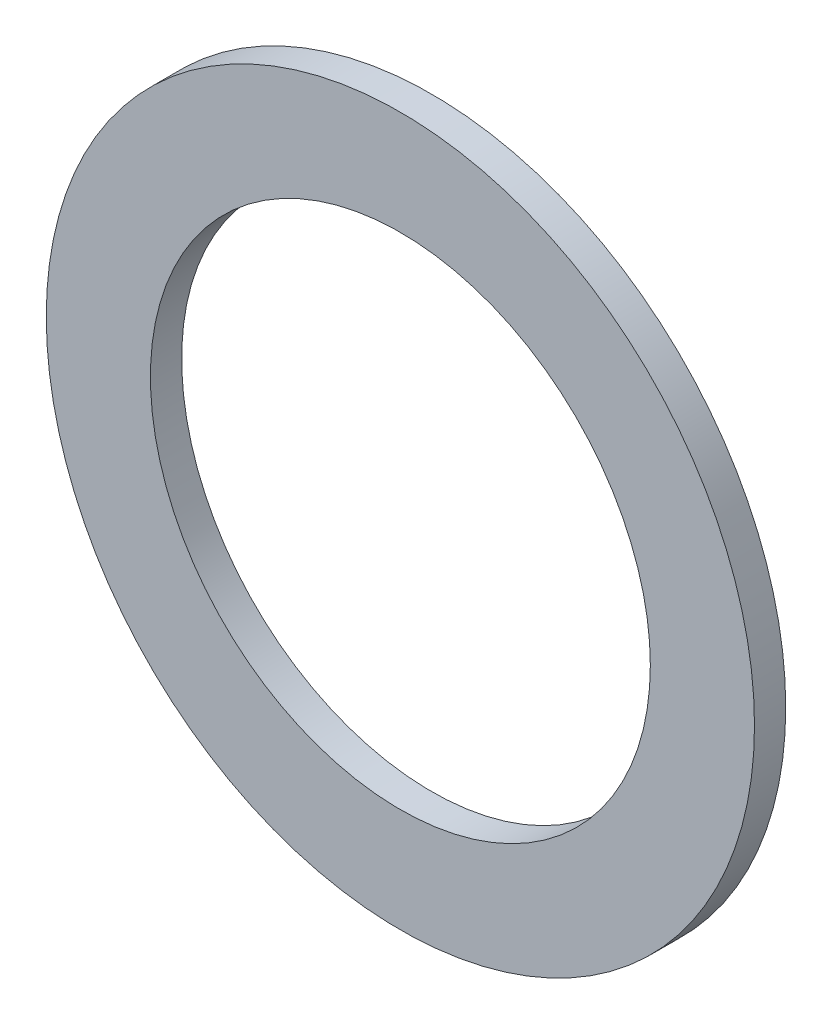
from build123d import *

# Parameters (mm, degrees)
SKETCH_1_R      = 17
SKETCH_1_R_2    = 12
EXTRUDE_1_DEPTH = 1.5


with BuildPart() as part:
    # Эскиз1 → Вытянуть-Тонкостенный1 (new body)
    with BuildSketch(Plane.XY):
        Circle(SKETCH_1_R)
        Circle(SKETCH_1_R_2, mode=Mode.SUBTRACT)
    extrude(amount=EXTRUDE_1_DEPTH)


solid = part.part
